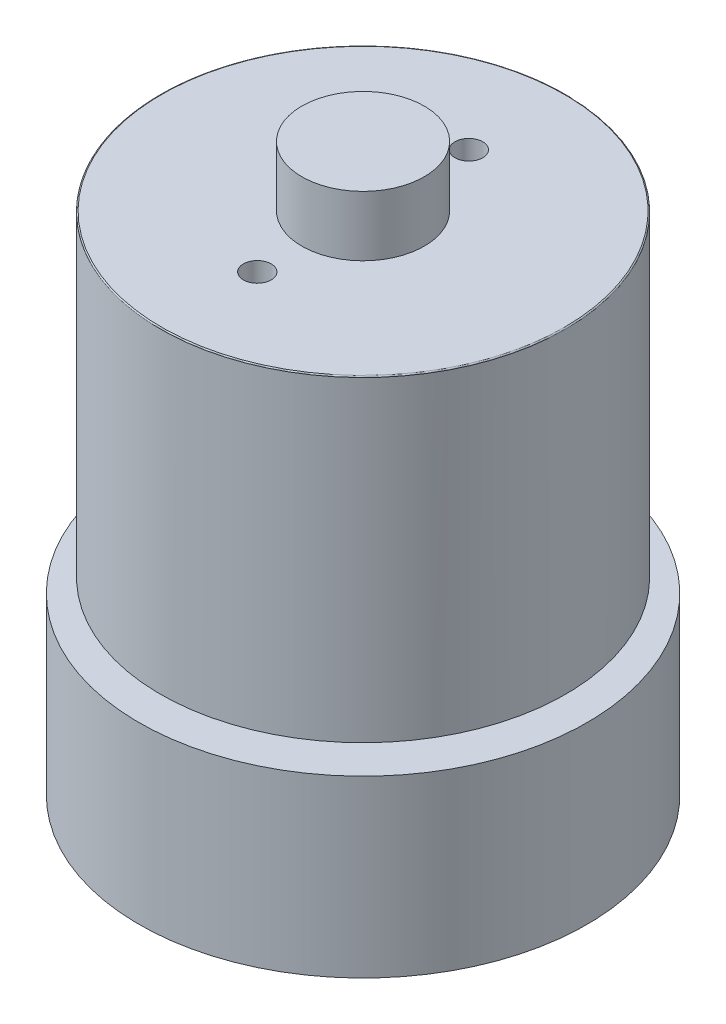
from build123d import *

# Parameters (mm, degrees)
M3X0_5_TAPPED_HOLE1_D               = 2.5
M3X0_5_TAPPED_HOLE1_DEPTH           = 5
M3X0_5_TAPPED_HOLE1_TIP             = 0.751075774
M3X0_5_TAPPED_HOLE1_ON_FACE_2_D     = 2.5
M3X0_5_TAPPED_HOLE1_ON_FACE_2_DEPTH = 5
M3X0_5_TAPPED_HOLE1_ON_FACE_2_TIP   = 0.751075774
FILLET1_R                           = 0.1


with BuildPart() as part:
    # Sketch1 → Revolve1 (revolve)
    with BuildSketch(Plane.XY):
        Polygon((0, 0), (20.115, 0), (20.115, 15.7), (10.115, 15.7), (10.115, 16.95), (18.2, 16.95), (18.2, 45.45), (5.5, 45.45), (5.5, 50.85), (0, 50.85), align=None)
    revolve(axis=Axis((0, 50.85, 0), (0, -1, 0)))

    # M3x0.5 Tapped Hole1
    with Locations(Plane(origin=(0, 45.45, -9.5), x_dir=(1, 0, 0), z_dir=(0, 1, 0))):
        with Locations((0, 0), (0, -19)):
            Hole(M3X0_5_TAPPED_HOLE1_D / 2, depth=M3X0_5_TAPPED_HOLE1_DEPTH)
            with Locations((0, 0, -(M3X0_5_TAPPED_HOLE1_DEPTH + M3X0_5_TAPPED_HOLE1_TIP / 2))):  # 118° drill point
                Cone(0, M3X0_5_TAPPED_HOLE1_D / 2, M3X0_5_TAPPED_HOLE1_TIP, mode=Mode.SUBTRACT)

    # M3x0.5 Tapped Hole1 on face 2
    with Locations(Plane(origin=(-16, 0, 0), x_dir=(0, 0, -1), z_dir=(0, -1, 0))):
        with Locations((0, 0), (0, 32)):
            Hole(M3X0_5_TAPPED_HOLE1_ON_FACE_2_D / 2, depth=M3X0_5_TAPPED_HOLE1_ON_FACE_2_DEPTH)
            with Locations((0, 0, -(M3X0_5_TAPPED_HOLE1_ON_FACE_2_DEPTH + M3X0_5_TAPPED_HOLE1_ON_FACE_2_TIP / 2))):  # 118° drill point
                Cone(0, M3X0_5_TAPPED_HOLE1_ON_FACE_2_D / 2, M3X0_5_TAPPED_HOLE1_ON_FACE_2_TIP, mode=Mode.SUBTRACT)

    # Fillet1
    fillet1_edges = [part.edges().sort_by_distance(p)[0] for p in [
        (-18.2, 45.45, 0),
    ]]
    fillet(fillet1_edges, radius=FILLET1_R)


solid = part.part
